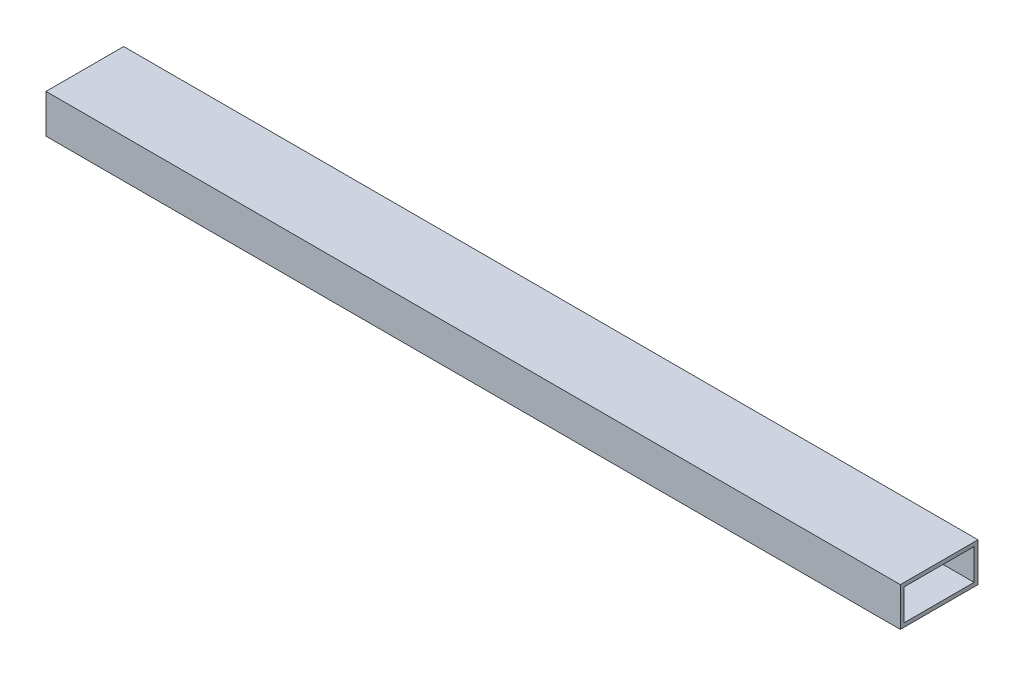
from build123d import *

# Parameters (mm, degrees)
SKETCH1_W           = 558.8
SKETCH1_H           = 50.8
BOSS_EXTRUDE1_DEPTH = 25.4
SKETCH2_W           = 45.72
SKETCH2_H           = 20.32
CUT_EXTRUDE1_DEPTH  = 558.8


with BuildPart() as part:
    # Sketch1 → Boss-Extrude1 (new body)
    with BuildSketch(Plane(origin=(0, 0, 0), x_dir=(1, 0, 0), z_dir=(0, 1, 0))):
        Rectangle(SKETCH1_W, SKETCH1_H)
    extrude(amount=BOSS_EXTRUDE1_DEPTH)

    # Sketch2 → Cut-Extrude1 (cut)
    with BuildSketch(Plane(origin=(279.4, 0, 0), x_dir=(0, 0, -1), z_dir=(1, 0, 0))):
        with Locations((0, 12.7)):
            Rectangle(SKETCH2_W, SKETCH2_H)
    extrude(amount=-CUT_EXTRUDE1_DEPTH, mode=Mode.SUBTRACT)


solid = part.part
